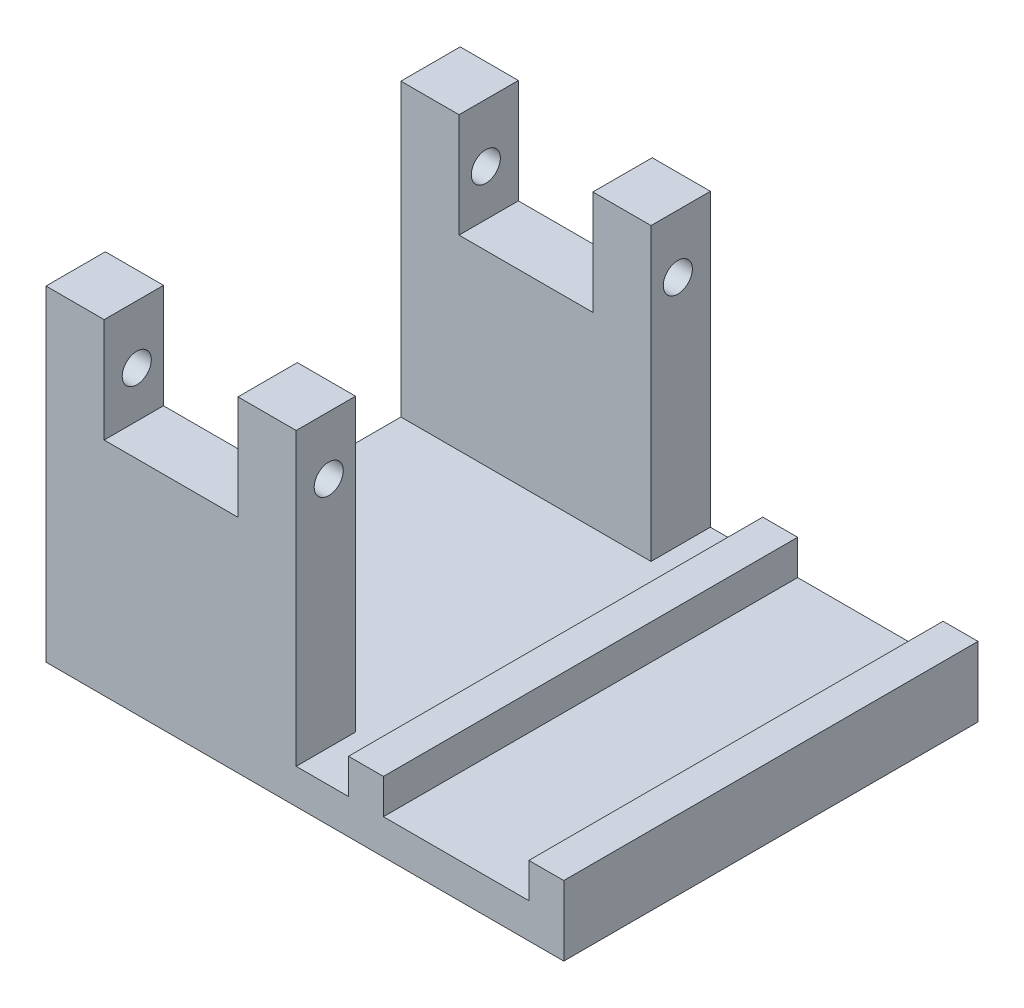
from build123d import *

# Parameters (mm, degrees)
SKETCH1_W           = 36.5
SKETCH1_H           = 35.6
BOSS_EXTRUDE1_DEPTH = 3
SKETCH2_W           = 3
SKETCH2_H           = 5.1
BOSS_EXTRUDE2_DEPTH = 23
SKETCH3_R           = 1.35
CUT_EXTRUDE1_DEPTH  = 37.5
SKETCH4_W           = 35.6
SKETCH4_H           = 3
BOSS_EXTRUDE3_DEPTH = 12.5
SKETCH5_W           = 3
SKETCH5_H           = 35.6
BOSS_EXTRUDE4_DEPTH = 6
SKETCH9_W           = 21.5
SKETCH9_H           = 5.1
BOSS_EXTRUDE6_DEPTH = 25
SKETCH10_R          = 1.25
CUT_EXTRUDE4_DEPTH  = 45.5
SKETCH11_W          = 3
SKETCH11_H          = 23
CUT_EXTRUDE5_DEPTH  = 36.6
SKETCH12_W          = 11.5
SKETCH12_H          = 8.963057692
CUT_EXTRUDE6_DEPTH  = 36.6
SKETCH13_W          = 3
SKETCH13_H          = 35.6
BOSS_EXTRUDE7_DEPTH = 3
SKETCH15_W          = 23
SKETCH15_H          = 35.6
CUT_EXTRUDE9_DEPTH  = 6


with BuildPart() as part:
    # Sketch1 → Boss-Extrude1 (new body)
    with BuildSketch(Plane(origin=(0, 0, 0), x_dir=(1, 0, 0), z_dir=(0, 1, 0))):
        Rectangle(SKETCH1_W, SKETCH1_H)
    extrude(amount=BOSS_EXTRUDE1_DEPTH)

    # Sketch2 → Boss-Extrude2 (add)
    with BuildSketch(Plane(origin=(0, 3, 0), x_dir=(1, 0, 0), z_dir=(0, 1, 0))):
        with Locations((-16.75, 15.25)):
            Rectangle(SKETCH2_W, SKETCH2_H)
        with Locations((-16.75, -15.25)):
            Rectangle(SKETCH2_W, SKETCH2_H)
        with Locations((16.75, 15.25)):
            Rectangle(SKETCH2_W, SKETCH2_H)
        with Locations((16.75, -15.25)):
            Rectangle(SKETCH2_W, SKETCH2_H)
    extrude(amount=BOSS_EXTRUDE2_DEPTH)

    # Sketch3 → Cut-Extrude1 (cut, through all)
    with BuildSketch(Plane(origin=(18.25, 0, 0), x_dir=(0, 0, -1), z_dir=(1, 0, 0))):
        with Locations((-15, 23)):
            Circle(SKETCH3_R)
        with Locations((15, 23)):
            Circle(SKETCH3_R)
    extrude(amount=-CUT_EXTRUDE1_DEPTH, mode=Mode.SUBTRACT)

    # Sketch4 → Boss-Extrude3 (add)
    with BuildSketch(Plane(origin=(18.25, 0, 0), x_dir=(0, 0, -1), z_dir=(1, 0, 0))):
        with Locations((0, 1.5)):
            Rectangle(SKETCH4_W, SKETCH4_H)
    boss_extrude3 = extrude(amount=BOSS_EXTRUDE3_DEPTH)

    # Mirror1: Boss-Extrude3 across plane
    add(boss_extrude3.mirror(Plane(origin=(0, 0, 0), x_dir=(0, 0, 1), z_dir=(1, 0, 0))))

    # Sketch5 → Boss-Extrude4 (add)
    with BuildSketch(Plane.XZ):
        with Locations((32.25, 0)):
            Rectangle(SKETCH5_W, SKETCH5_H)
    boss_extrude4 = extrude(amount=-BOSS_EXTRUDE4_DEPTH)

    # Mirror2: Boss-Extrude4 across plane
    add(boss_extrude4.mirror(Plane(origin=(0, 0, 0), x_dir=(0, 0, 1), z_dir=(1, 0, 0))))

    # Sketch9 → Boss-Extrude6 (add)
    with BuildSketch(Plane(origin=(0, 3, 0), x_dir=(1, 0, 0), z_dir=(0, 1, 0))):
        with Locations((0, 15.25)):
            Rectangle(SKETCH9_W, SKETCH9_H)
        with Locations((0, -15.25)):
            Rectangle(SKETCH9_W, SKETCH9_H)
    extrude(amount=BOSS_EXTRUDE6_DEPTH)

    # Sketch10 → Cut-Extrude4 (cut, through all)
    with BuildSketch(Plane(origin=(10.75, 0, 0), x_dir=(0, 0, -1), z_dir=(1, 0, 0))):
        with Locations((15, 23)):
            Circle(SKETCH10_R)
        with Locations((-15, 23)):
            Circle(SKETCH10_R)
    extrude(amount=-CUT_EXTRUDE4_DEPTH, mode=Mode.SUBTRACT)

    # Sketch11 → Cut-Extrude5 (cut, through all)
    with BuildSketch(Plane(origin=(0, 0, -17.8), x_dir=(-1, 0, 0), z_dir=(0, 0, -1))):
        with Locations((-16.75, 14.5)):
            Rectangle(SKETCH11_W, SKETCH11_H)
        with Locations((16.75, 14.5)):
            Rectangle(SKETCH11_W, SKETCH11_H)
    extrude(amount=-CUT_EXTRUDE5_DEPTH, mode=Mode.SUBTRACT)

    # Sketch12 → Cut-Extrude6 (cut, through all)
    with BuildSketch(Plane(origin=(0, 0, -17.8), x_dir=(-1, 0, 0), z_dir=(0, 0, -1))):
        with Locations((0, 23.518471154)):
            Rectangle(SKETCH12_W, SKETCH12_H)
    extrude(amount=-CUT_EXTRUDE6_DEPTH, mode=Mode.SUBTRACT)

    # Sketch13 → Boss-Extrude7 (add)
    with BuildSketch(Plane(origin=(0, 3, 0), x_dir=(1, 0, 0), z_dir=(0, 1, 0))):
        with Locations((16.75, 0)):
            Rectangle(SKETCH13_W, SKETCH13_H)
    extrude(amount=BOSS_EXTRUDE7_DEPTH)

    # Sketch15 → Cut-Extrude9 (cut)
    with BuildSketch(Plane(origin=(0, 6, 0), x_dir=(1, 0, 0), z_dir=(0, 1, 0))):
        with Locations((-22.25, 0)):
            Rectangle(SKETCH15_W, SKETCH15_H)
    extrude(amount=-CUT_EXTRUDE9_DEPTH, mode=Mode.SUBTRACT)


solid = part.part
